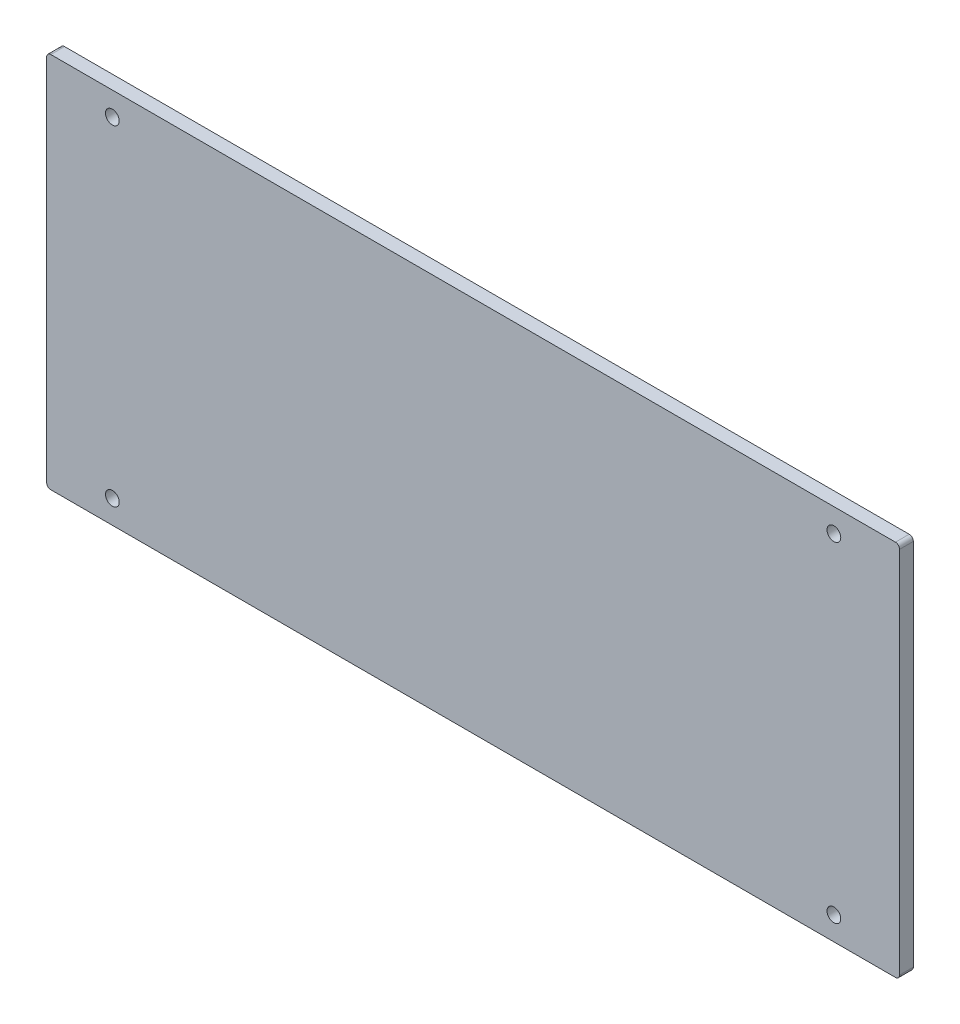
from build123d import *

# Parameters (mm, degrees)
BOSS_EXTRU_1_DEPTH      = 5
ESQUISSE2_R             = 2.5
ENL_V_MAT_EXTRU_1_DEPTH = 5


with BuildPart() as part:
    # Esquisse1 → Boss.-Extru.1 (new body)
    with BuildSketch(Plane.XY):
        with BuildLine():
            Line((-153.5, -68.5), (153.5, -68.5))
            ThreePointArc((153.5, -68.5), (154.560660172, -68.060660172), (155, -67))
            Line((155, -67), (155, 67))
            ThreePointArc((155, 67), (154.560660172, 68.060660172), (153.5, 68.5))
            Line((153.5, 68.5), (-153.5, 68.5))
            ThreePointArc((-153.5, 68.5), (-154.560660172, 68.060660172), (-155, 67))
            Line((-155, 67), (-155, -67))
            ThreePointArc((-155, -67), (-154.560660172, -68.060660172), (-153.5, -68.5))
        make_face()
    extrude(amount=BOSS_EXTRU_1_DEPTH)

    # Esquisse2 → Enlèv. mat.-Extru.1 (cut)
    with BuildSketch(Plane(origin=(0, 0, 0), x_dir=(-1, 0, 0), z_dir=(0, 0, -1))):
        with Locations((-131.119201541, -60)):
            Circle(ESQUISSE2_R)
        with Locations((-131.119201541, 60)):
            Circle(ESQUISSE2_R)
        with Locations((131.119201541, 60)):
            Circle(ESQUISSE2_R)
        with Locations((131.119201541, -60)):
            Circle(ESQUISSE2_R)
    extrude(amount=-ENL_V_MAT_EXTRU_1_DEPTH, mode=Mode.SUBTRACT)


solid = part.part
